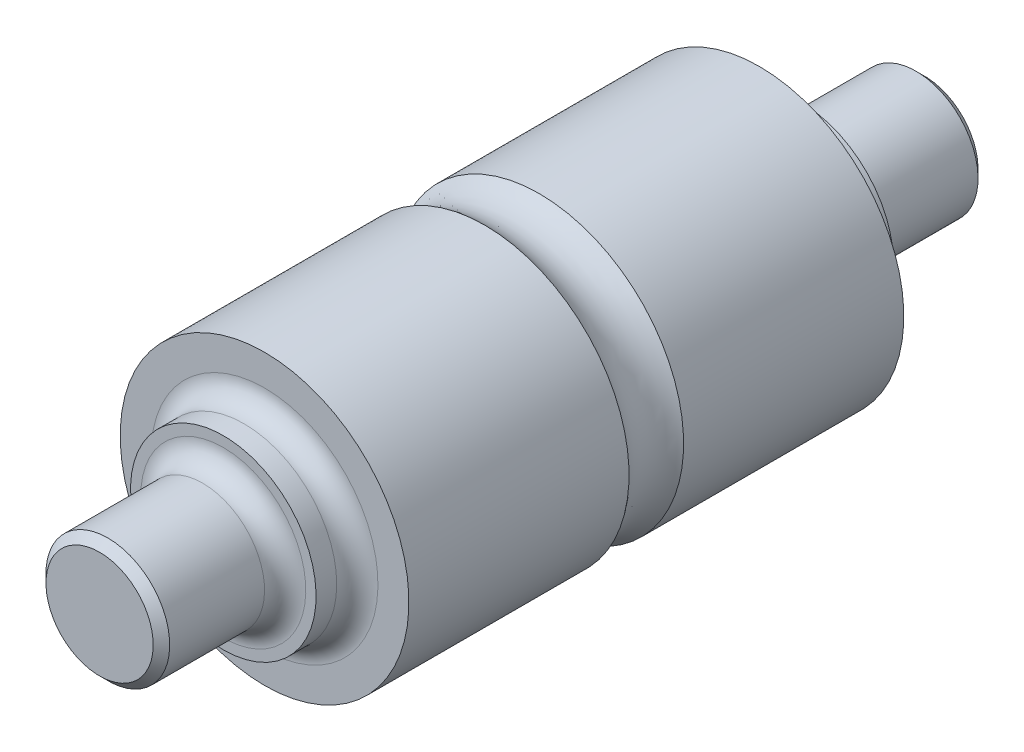
from build123d import *

# Parameters (mm, degrees)
CHANFRO1_SIZE = 2
FILETE1_R     = 5


with BuildPart() as part:
    # Esboço1 → Revolução1 (revolve)
    with BuildSketch(Plane(origin=(0, 0, 0), x_dir=(0, 0, -1), z_dir=(1, 0, 0))):
        with BuildLine():
            Line((100, 0), (100, 15))
            Line((100, 15), (70, 15))
            Line((70, 15), (70, 22.5))
            Line((70, 22.5), (60, 22.5))
            Line((60, 22.5), (60, 35))
            Line((60, 35), (6.614378278, 35))
            ThreePointArc((6.614378278, 35), (0, 32.5), (-6.614378278, 35))
            Line((-6.614378278, 35), (-60, 35))
            Line((-60, 35), (-60, 22.5))
            Line((-60, 22.5), (-70, 22.5))
            Line((-70, 22.5), (-70, 15))
            Line((-70, 15), (-100, 15))
            Line((-100, 15), (-100, 0))
            Line((-100, 0), (100, 0))
        make_face()
    revolve(axis=Axis((0, 0, 100), (0, 0, -1)))

    # Chanfro1
    chanfro1_edges = [part.edges().sort_by_distance(p)[0] for p in [
        (0, -15, 100),
        (0, -15, -100),
    ]]
    chamfer(chanfro1_edges, length=CHANFRO1_SIZE)

    # Filete1
    filete1_edges = [part.edges().sort_by_distance(p)[0] for p in [
        (0, -15, 70),
        (0, -22.5, 60),
        (0, -22.5, -60),
        (0, -15, -70),
    ]]
    fillet(filete1_edges, radius=FILETE1_R)


solid = part.part
